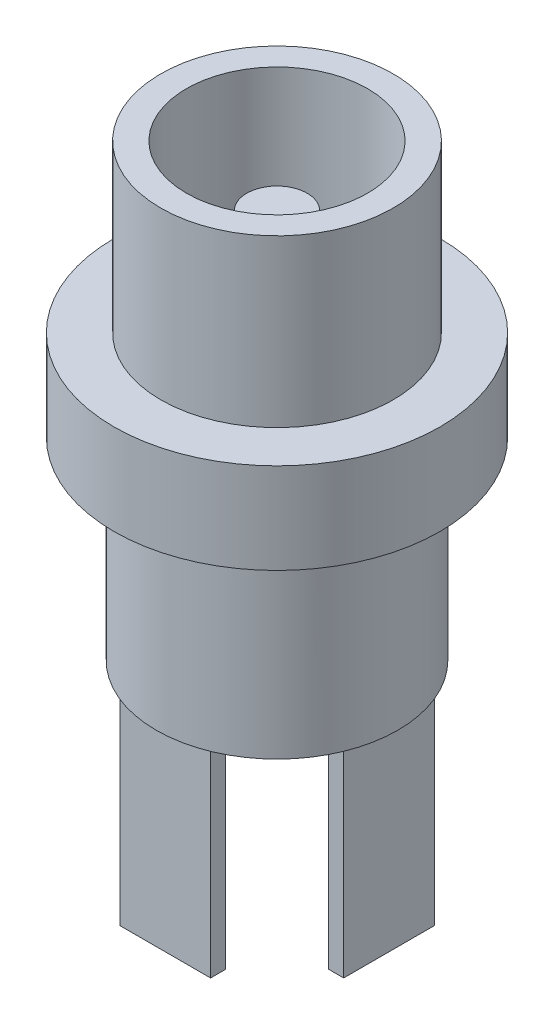
from build123d import *

# Parameters (mm, degrees)
ESQUISSE1_R             = 5.4
BOSS_EXTRU_1_DEPTH      = 3
ESQUISSE2_R             = 3.85
BOSS_EXTRU_2_DEPTH      = 5.5
ESQUISSE3_R             = 4
BOSS_EXTRU_3_DEPTH      = 6.4
ESQUISSE4_W             = 3
ESQUISSE4_H             = 0.5
ESQUISSE4_W_2           = 0.5
ESQUISSE4_H_2           = 3
BOSS_EXTRU_4_DEPTH      = 6.5
ESQUISSE5_R             = 3
ENL_V_MAT_EXTRU_1_DEPTH = 10
ESQUISSE6_R             = 1
BOSS_EXTRU_5_DEPTH      = 8


with BuildPart() as part:
    # Esquisse1 → Boss.-Extru.1 (new body)
    with BuildSketch(Plane(origin=(0, 0, 0), x_dir=(1, 0, 0), z_dir=(0, 1, 0))):
        Circle(ESQUISSE1_R)
    extrude(amount=BOSS_EXTRU_1_DEPTH)

    # Esquisse2 → Boss.-Extru.2 (add)
    with BuildSketch(Plane(origin=(0, 3, 0), x_dir=(1, 0, 0), z_dir=(0, 1, 0))):
        Circle(ESQUISSE2_R)
    extrude(amount=BOSS_EXTRU_2_DEPTH)

    # Esquisse3 → Boss.-Extru.3 (add)
    with BuildSketch(Plane.XZ):
        Circle(ESQUISSE3_R)
    extrude(amount=BOSS_EXTRU_3_DEPTH)

    # Esquisse4 → Boss.-Extru.4 (add)
    with BuildSketch(Plane.XZ.offset(6.4)):
        with Locations((0.005129852, -3.453606957)):
            Rectangle(ESQUISSE4_W, ESQUISSE4_H)
        with Locations((0.005129852, 3.453606957)):
            Rectangle(ESQUISSE4_W, ESQUISSE4_H)
        with Locations((3.458099244, 0)):
            Rectangle(ESQUISSE4_W_2, ESQUISSE4_H_2)
    extrude(amount=BOSS_EXTRU_4_DEPTH)

    # Esquisse5 → Enlèv. mat.-Extru.1 (cut)
    with BuildSketch(Plane(origin=(0, 8.5, 0), x_dir=(1, 0, 0), z_dir=(0, 1, 0))):
        Circle(ESQUISSE5_R)
    extrude(amount=-ENL_V_MAT_EXTRU_1_DEPTH, mode=Mode.SUBTRACT)

    # Esquisse6 → Boss.-Extru.5 (add)
    with BuildSketch(Plane(origin=(0, -1.5, 0), x_dir=(1, 0, 0), z_dir=(0, 1, 0))):
        Circle(ESQUISSE6_R)
    extrude(amount=BOSS_EXTRU_5_DEPTH)


solid = part.part
